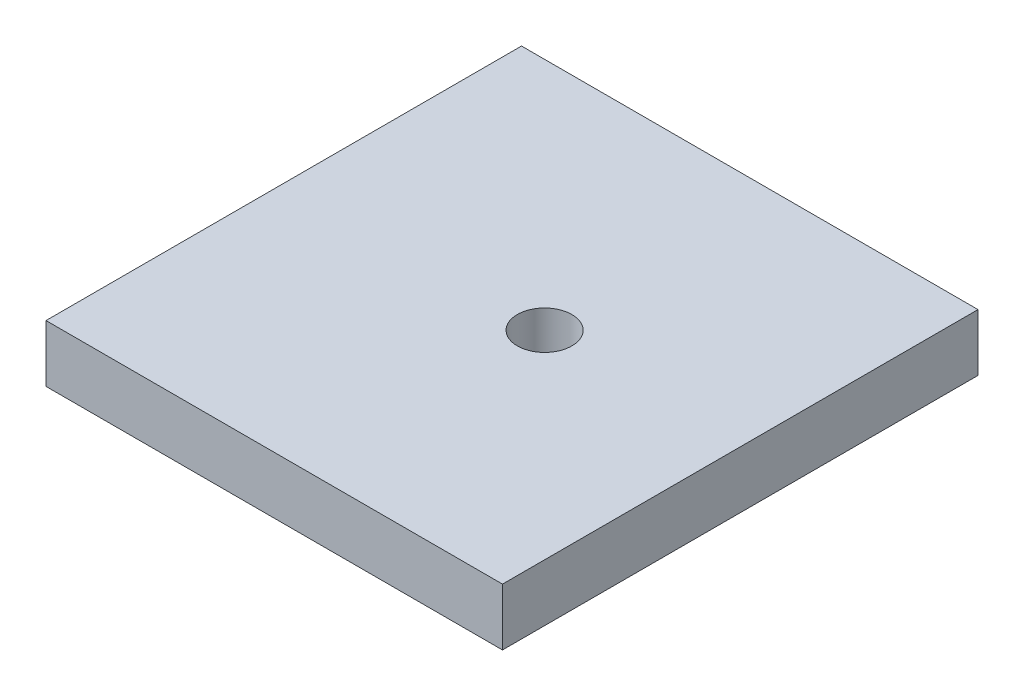
from build123d import *

# Parameters (mm, degrees)
SKETCH1_W           = 36
SKETCH1_H           = 37.5
BOSS_EXTRUDE1_DEPTH = 4.5
SKETCH2_R           = 2.15
CUT_EXTRUDE1_DEPTH  = 5.5


with BuildPart() as part:
    # Sketch1 → Boss-Extrude1 (new body)
    with BuildSketch(Plane(origin=(0, 0, 0), x_dir=(1, 0, 0), z_dir=(0, 1, 0))):
        with Locations((-6.66449877, -9.135025903)):
            Rectangle(SKETCH1_W, SKETCH1_H)
    extrude(amount=BOSS_EXTRUDE1_DEPTH)

    # Sketch2 → Cut-Extrude1 (cut, through all)
    with BuildSketch(Plane(origin=(0, 4.5, 0), x_dir=(1, 0, 0), z_dir=(0, 1, 0))):
        with Locations((-4.34449877, -8.885025903)):
            Circle(SKETCH2_R)
    extrude(amount=-CUT_EXTRUDE1_DEPTH, mode=Mode.SUBTRACT)


solid = part.part
